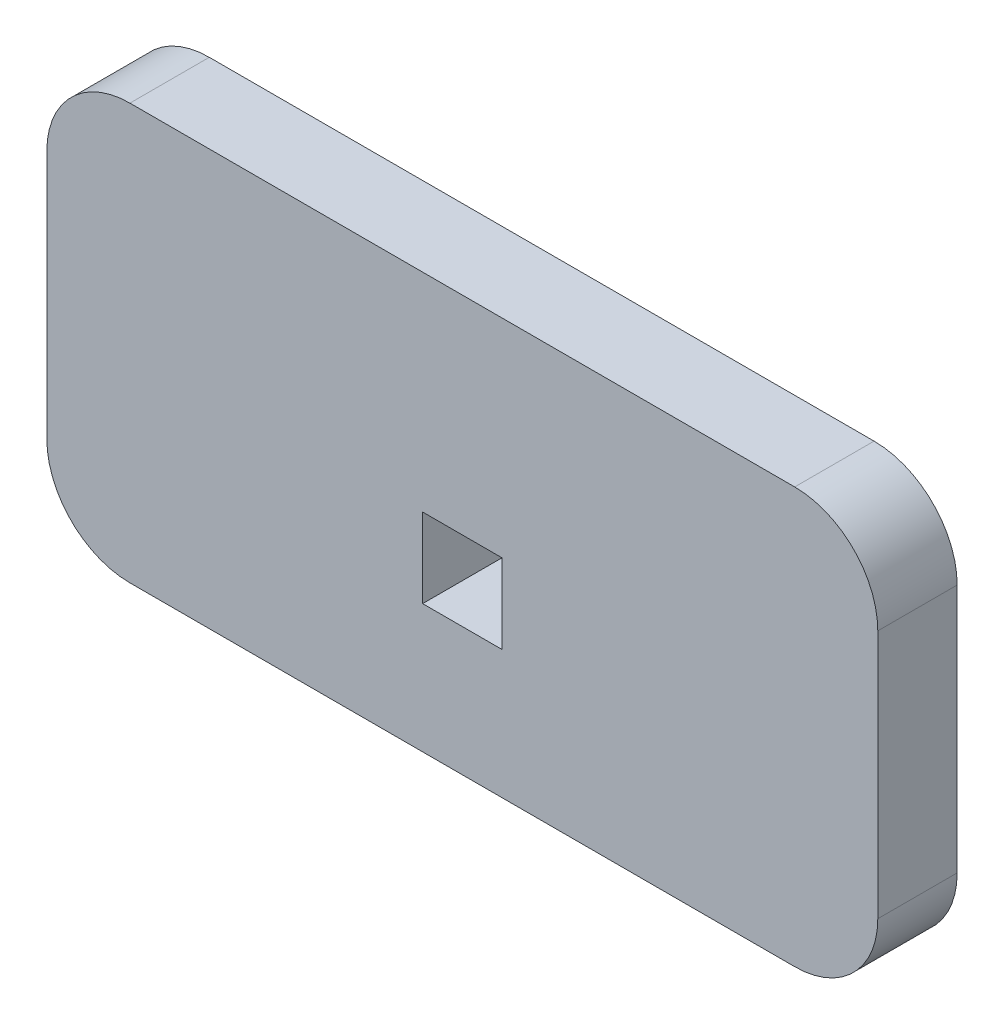
from build123d import *

# Parameters (mm, degrees)
BOSS_EXTRUDE1_DEPTH = 4.7752
SKETCH2_W           = 4.7752
SKETCH2_H           = 4.7752
CUT_EXTRUDE1_DEPTH  = 5.7752


with BuildPart() as part:
    # Sketch1 → Boss-Extrude1 (new body)
    with BuildSketch(Plane.XY):
        with BuildLine():
            Line((5, -4.7752), (45, -4.7752))
            ThreePointArc((45, -4.7752), (48.535533906, -3.310733906), (50, 0.2248))
            Line((50, 0.2248), (50, 15.2248))
            ThreePointArc((50, 15.2248), (48.535533906, 18.760333906), (45, 20.2248))
            Line((45, 20.2248), (5, 20.2248))
            ThreePointArc((5, 20.2248), (1.464466094, 18.760333906), (0, 15.2248))
            Line((0, 15.2248), (0, 0.2248))
            ThreePointArc((0, 0.2248), (1.464466094, -3.310733906), (5, -4.7752))
        make_face()
    extrude(amount=BOSS_EXTRUDE1_DEPTH)

    # Sketch2 → Cut-Extrude1 (cut, through all)
    with BuildSketch(Plane.XY.offset(4.7752)):
        with Locations((25, 5.3372)):
            Rectangle(SKETCH2_W, SKETCH2_H)
    extrude(amount=-CUT_EXTRUDE1_DEPTH, mode=Mode.SUBTRACT)


solid = part.part
